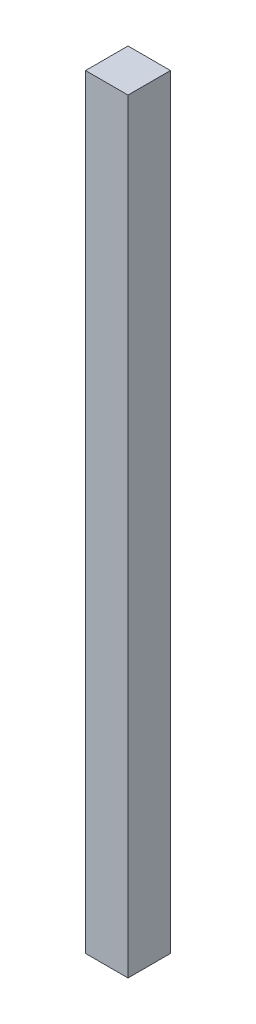
from build123d import *

# Parameters (mm, degrees)
ESBO_O2_W                = 50
ESBO_O2_H                = 50
RESSALTO_EXTRUS_O1_DEPTH = 900


with BuildPart() as part:
    # Esboço2 → Ressalto-extrusão1 (new body)
    with BuildSketch(Plane(origin=(0, 0, 0), x_dir=(1, 0, 0), z_dir=(0, 1, 0))):
        with Locations((-25, 4.076086957)):
            Rectangle(ESBO_O2_W, ESBO_O2_H)
    extrude(amount=RESSALTO_EXTRUS_O1_DEPTH)


solid = part.part
